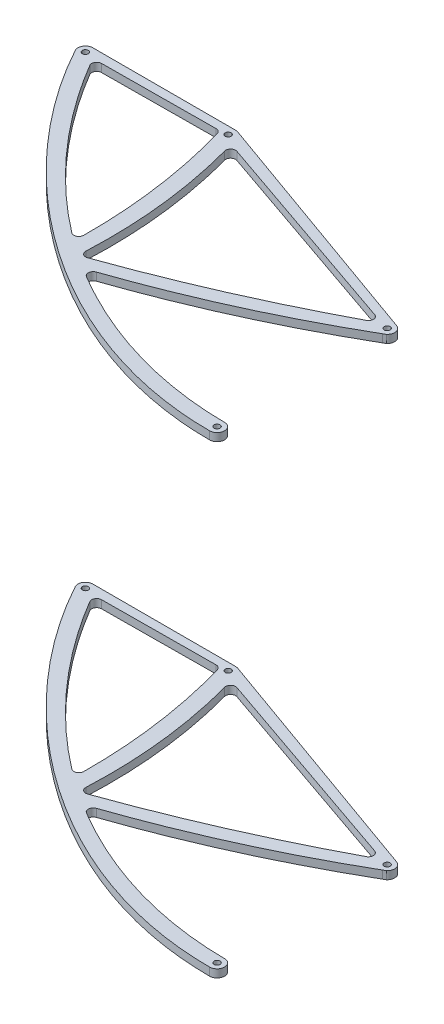
from build123d import *

# Parameters (mm, degrees)
SZKIC1_R                    = 3
DODANIE_WYCI_GNI_CIE1_DEPTH = 8
WYTNIJ_WYCI_GNI_CIE1_DEPTH  = 10


with BuildPart() as part:
    # Szkic1 → Dodanie-wyciągnięcie1 (new body)
    with BuildSketch(Plane(origin=(0, -230, 0), x_dir=(1, 0, 0), z_dir=(0, 1, 0))):
        with BuildLine():
            Line((-860.283761323, -96.903028566), (-716.367623737, -96.903028566))
            ThreePointArc((-716.367623737, -96.903028566), (-715.087689008, -97.01305109), (-713.845306719, -97.339890675))
            Line((-713.845306719, -97.339890675), (-464.622728154, -186.339760243))
            ThreePointArc((-464.622728154, -186.339760243), (-461.014491459, -189.082445474), (-459.645045171, -193.402898133))
            Line((-459.645045171, -193.402898133), (-459.645045171, -364.820100819))
            ThreePointArc((-459.645045171, -364.820100819), (-461.841744312, -370.123401678), (-467.145045171, -372.320100819))
            add(Edge.make_bspline(
                [(-866.570954117, -108.492185785), (-792.00641608, -245.378469281), (-630.821489356, -372.320100819), (-467.145045171, -372.320100819)],
                knots=[0, 0, 0, 0, 1, 1, 1, 1], degree=3))
            ThreePointArc((-866.570954117, -108.492185785), (-866.876131122, -100.826625285), (-860.283761323, -96.903028566))
        make_face()
        with Locations((-860.283761323, -104.403028566)):
            Circle(SZKIC1_R, mode=Mode.SUBTRACT)
        with Locations((-716.367623737, -104.403028566)):
            Circle(SZKIC1_R, mode=Mode.SUBTRACT)
        with Locations((-467.145045171, -364.820100819)):
            Circle(SZKIC1_R, mode=Mode.SUBTRACT)
        with Locations((-467.145045171, -193.402898133)):
            Circle(SZKIC1_R, mode=Mode.SUBTRACT)
    extrude(amount=-DODANIE_WYCI_GNI_CIE1_DEPTH)

    # Szkic3 → Wytnij-wyciągnięcie1 (cut)
    with BuildSketch(Plane(origin=(0, -230, 0), x_dir=(1, 0, 0), z_dir=(0, 1, 0))):
        with BuildLine():
            add(Edge.make_bspline(
                [(-709.248534219, -269.07668038), (-722.179737317, -259.210827847), (-775.604005814, -214.162441173), (-819.746188645, -158.864006657), (-846.480343559, -113.712350137)],
                knots=[0.543324795, 0.543324795, 0.543324795, 0.543324795, 0.643434608, 0.972151832, 0.972151832, 0.972151832, 0.972151832], degree=3))
            ThreePointArc((-846.480343559, -113.712350137), (-846.530624115, -108.704381299), (-842.213905835, -106.16504609))
            Line((-842.213905835, -106.16504609), (-727.592781287, -105.340783466))
            ThreePointArc((-727.592781287, -105.340783466), (-724.563211054, -106.335873539), (-722.751263872, -108.959868102))
            add(Edge.make_bspline(
                [(-701.215793155, -265.133388319), (-701.077439027, -243.423735214), (-703.820061872, -190.825193742), (-714.078774615, -139.14281138), (-722.751263872, -108.959868102)],
                knots=[0.056948511, 0.056948511, 0.056948511, 0.056948511, 0.434451685, 0.97809878, 0.97809878, 0.97809878, 0.97809878], degree=3))
            ThreePointArc((-701.215793155, -265.133388319), (-704.012349781, -269.589874199), (-709.248534219, -269.07668038))
        make_face()
        with BuildLine():
            add(Edge.make_bspline(
                [(-686.319170472, -277.860544771), (-685.302920026, -255.26935331), (-686.39468841, -202.387194664), (-695.705663637, -150.367651954), (-703.790790165, -120.703989623)],
                knots=[0.039856792, 0.039856792, 0.039856792, 0.039856792, 0.403728138, 0.897512765, 0.897512765, 0.897512765, 0.897512765], degree=3))
            ThreePointArc((-703.790790165, -120.703989623), (-702.383503754, -115.738687501), (-697.33606889, -114.662545549))
            Line((-697.33606889, -114.662545549), (-485.252395428, -187.832196761))
            ThreePointArc((-485.252395428, -187.832196761), (-481.897987574, -192.173154702), (-484.544842355, -196.978373497))
            add(Edge.make_bspline(
                [(-679.646661827, -282.79541905), (-646.392972029, -270.951909358), (-580.318683117, -244.722081668), (-516.306620405, -213.782500871), (-484.544842355, -196.978373497)],
                knots=[0.03217455, 0.03217455, 0.03217455, 0.03217455, 0.487326478, 0.950667765, 0.950667765, 0.950667765, 0.950667765], degree=3))
            ThreePointArc((-679.646661827, -282.79541905), (-684.297353643, -282.105250194), (-686.319170472, -277.860544771))
        make_face()
        with BuildLine():
            Line((-459.645045171, -364.820100819), (-459.645045171, -193.402898133))
            ThreePointArc((-459.645045171, -193.402898133), (-460.337418676, -196.550313185), (-462.28670424, -199.116611759))
            Line((-462.28670424, -199.116611759), (-464.622728154, -200.466036024))
            add(Edge.make_bspline(
                [(-464.622728154, -200.466036024), (-496.556052513, -218.91259494), (-561.198503951, -252.191994525), (-628.724382783, -279.099976613), (-662.828576381, -290.850183316)],
                knots=[0, 0, 0, 0, 0.481929693, 0.953574963, 0.953574963, 0.953574963, 0.953574963], degree=3))
            ThreePointArc((-662.828576381, -290.850183316), (-666.173575672, -295.065611568), (-663.757232459, -299.873952351))
            add(Edge.make_bspline(
                [(-465.564272351, -357.488582744), (-536.676618046, -357.101187386), (-603.973726194, -335.458782), (-663.757232459, -299.873952351)],
                knots=[0, 0, 0, 0, 0.430291094, 0.430291094, 0.430291094, 0.430291094], degree=3))
            ThreePointArc((-465.564272351, -357.488582744), (-461.309559067, -360.108720775), (-459.645045171, -364.820100819))
        make_face()
    extrude(amount=-WYTNIJ_WYCI_GNI_CIE1_DEPTH, mode=Mode.SUBTRACT)


with BuildPart() as body_2:
    # Lustro1: mirrored copy
    add(part.part.mirror(Plane.ZX))


solid = Compound([part.part, body_2.part])
